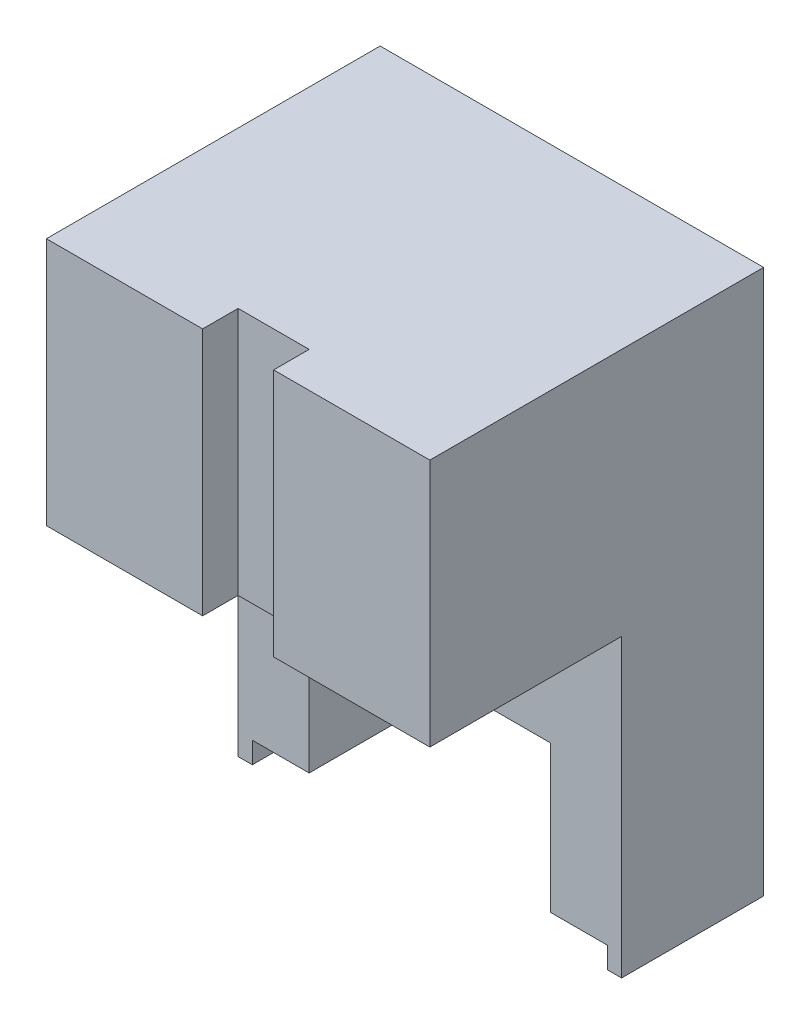
from build123d import *

# Parameters (mm, degrees)
EXTRUSION1_DEPTH = 20
ESQUISSE2_W      = 54
ESQUISSE2_H      = 35
EXTRUSION2_DEPTH = 27
ESQUISSE4_W      = 10
ESQUISSE4_H      = 5
EXTRUSION4_DEPTH = 77.66


with BuildPart() as part:
    # Esquisse1 → Extrusion1 (new body)
    with BuildSketch(Plane.XY):
        Polygon((0, 0), (-8, 0), (-8, 20.66), (-42, 20.66), (-42, 0), (-50, 0), (-50, -3), (-52, -3), (-52, 73.66), (2, 73.66), (2, -3), (0, -3), align=None)
    extrude(amount=EXTRUSION1_DEPTH)

    # Esquisse2 → Extrusion2 (add)
    with BuildSketch(Plane.XY.offset(20)):
        with Locations((-25, 56.16)):
            Rectangle(ESQUISSE2_W, ESQUISSE2_H)
    extrude(amount=EXTRUSION2_DEPTH)

    # Esquisse4 → Extrusion4 (cut, through all)
    with BuildSketch(Plane(origin=(0, 73.66, 0), x_dir=(1, 0, 0), z_dir=(0, 1, 0))):
        with Locations((-25, -44.5)):
            Rectangle(ESQUISSE4_W, ESQUISSE4_H)
    extrude(amount=-EXTRUSION4_DEPTH, mode=Mode.SUBTRACT)


solid = part.part
